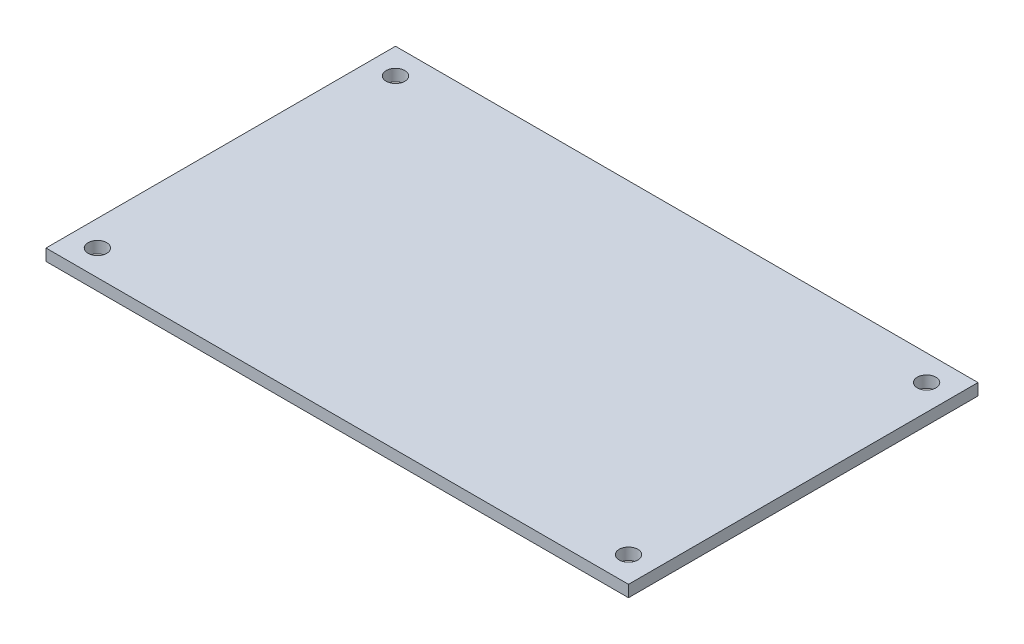
from build123d import *

# Parameters (mm, degrees)
SKETCH_1_W      = 100
SKETCH_1_H      = 60
SKETCH_1_R      = 1.6
EXTRUDE_1_DEPTH = 2


with BuildPart() as part:
    # Эскиз1 → Бобышка-Вытянуть1 (new body)
    with BuildSketch(Plane(origin=(0, 0, 0), x_dir=(1, 0, 0), z_dir=(0, 1, 0))):
        Rectangle(SKETCH_1_W, SKETCH_1_H)
        with Locations((-45.587653685, 25.587653685)):
            Circle(SKETCH_1_R, mode=Mode.SUBTRACT)
        with Locations((45.587653685, 25.587653685)):
            Circle(SKETCH_1_R, mode=Mode.SUBTRACT)
        with Locations((45.587653685, -25.587653685)):
            Circle(SKETCH_1_R, mode=Mode.SUBTRACT)
        with Locations((-45.587653685, -25.587653685)):
            Circle(SKETCH_1_R, mode=Mode.SUBTRACT)
    extrude(amount=EXTRUDE_1_DEPTH)


solid = part.part
